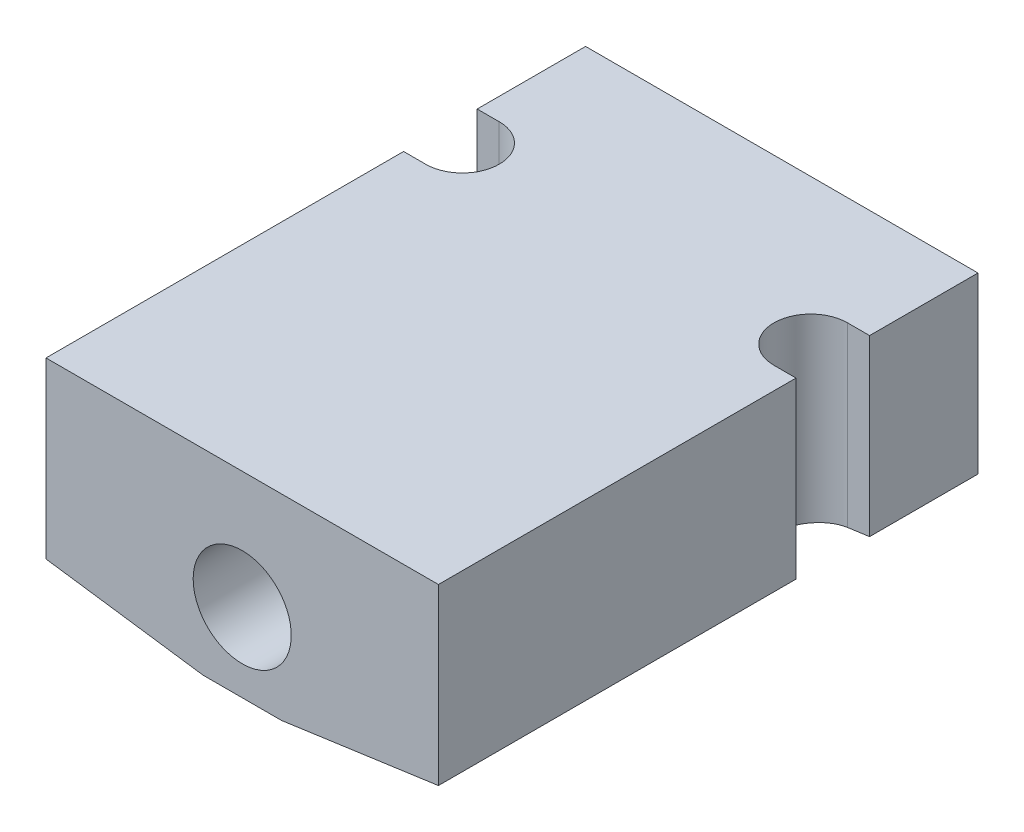
from build123d import *

# Parameters (mm, degrees)
SKETCH1_W                   = 25.4
SKETCH1_H                   = 12.7
EXTRUDE1_DEPTH              = 34.925
CHAMFER1_SIZE               = 10.16
CHAMFER1_SIZE2              = 1.427894881
F_1_4_0_25_DIAMETER_HOLE1_D = 6.35
EXTRUDE2_DEPTH              = 13.7


with BuildPart() as part:
    # Sketch1 → Extrude1 (new body)
    with BuildSketch(Plane.XY):
        Rectangle(SKETCH1_W, SKETCH1_H)
    extrude(amount=EXTRUDE1_DEPTH)

    # Chamfer1
    chamfer1_edges = [part.edges().sort_by_distance(p)[0] for p in [
        (12.7, -6.35, 17.4625),
        (-12.7, -6.35, 17.4625),
    ]]
    chamfer1_side = [part.faces().sort_by_distance(p)[0] for p in [
        (0, -6.35, 17.4625),
    ]]
    chamfer(chamfer1_edges, length=CHAMFER1_SIZE, length2=CHAMFER1_SIZE2, reference=chamfer1_side[0])

    # 1/4 (0.25) Diameter Hole1 (through all)
    with Locations(Plane(origin=(0, 0, 0), x_dir=(-1, 0, 0), z_dir=(0, 0, -1))):
        with Locations((0, -1.27)):
            Hole(F_1_4_0_25_DIAMETER_HOLE1_D / 2)

    # Sketch5 → Extrude2 (cut, through all)
    with BuildSketch(Plane(origin=(0, 6.35, 0), x_dir=(1, 0, 0), z_dir=(0, 1, 0))):
        with BuildLine():
            Line((-11.27125, -11.77925), (-12.7, -11.77925))
            Line((-12.7, -11.77925), (-12.7, -7.01675))
            Line((-12.7, -7.01675), (-11.27125, -7.01675))
            ThreePointArc((-11.27125, -7.01675), (-8.89, -9.398), (-11.27125, -11.77925))
        make_face()
    extrude2 = extrude(amount=-EXTRUDE2_DEPTH, mode=Mode.SUBTRACT)

    # Mirror1: Extrude2 across plane
    add(extrude2.mirror(Plane(origin=(0, 0, 0), x_dir=(0, 0, 1), z_dir=(1, 0, 0))), mode=Mode.SUBTRACT)


solid = part.part
